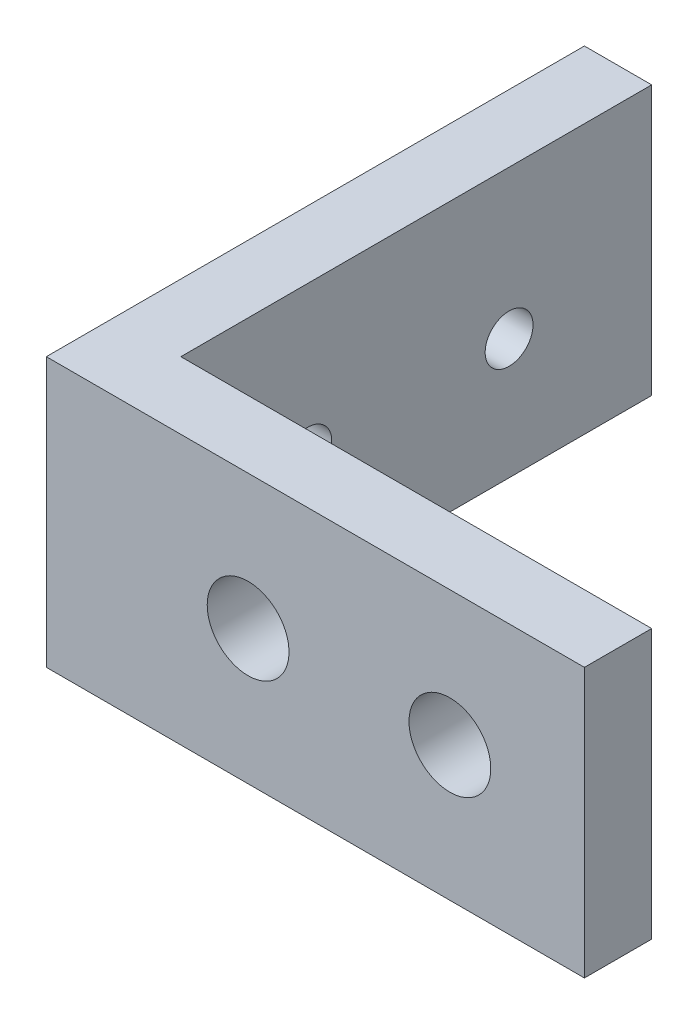
from build123d import *

# Parameters (mm, degrees)
BOSS_EXTRUDE1_DEPTH         = 12.7
F_24_0_152_DIAMETER_HOLE1_D = 3.8608
TAP_DRILL_FOR_4_40_TAP1_D   = 2.2606


with BuildPart() as part:
    # Sketch1 → Boss-Extrude1 (new body)
    with BuildSketch(Plane(origin=(0, 0, 0), x_dir=(1, 0, 0), z_dir=(0, 1, 0))):
        Polygon((-9.525, 12.7), (-9.525, -9.525), (12.7, -9.525), (12.7, -12.7), (-12.7, -12.7), (-12.7, 12.7), align=None)
    extrude(amount=BOSS_EXTRUDE1_DEPTH)

    # #24 (0.152) Diameter Hole1 (through all)
    with Locations(Plane(origin=(6.35, 6.35, 9.525), x_dir=(-1, 0, 0), z_dir=(0, 0, -1))):
        with Locations((0, 0), (9.525, 0)):
            Hole(F_24_0_152_DIAMETER_HOLE1_D / 2)

    # Tap Drill for #4-40 Tap1 (through all)
    with Locations(Plane(origin=(-12.7, 5.6896, -5.969), x_dir=(0, 0, -1), z_dir=(-1, 0, 0))):
        with Locations((0, 0), (-9.4996, 0)):
            Hole(TAP_DRILL_FOR_4_40_TAP1_D / 2)


solid = part.part
